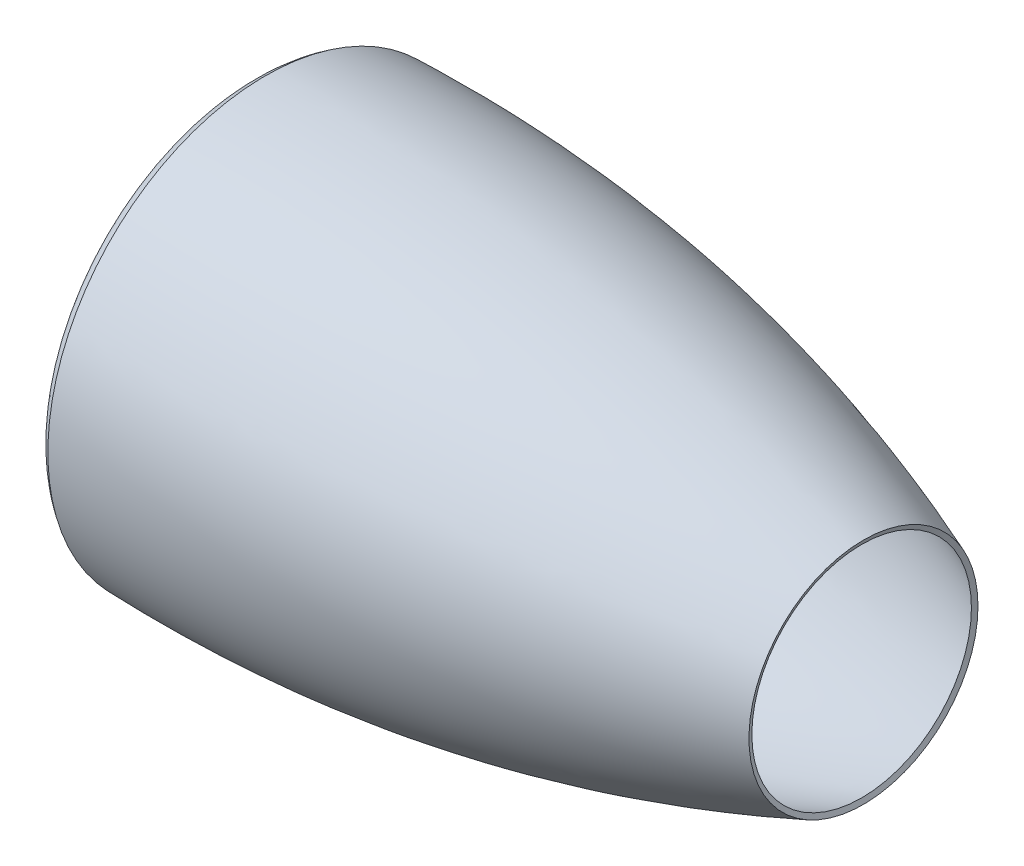
from build123d import *

# Parameters (mm, degrees)
THICKEN1_T1 = 5


with BuildPart() as body_1:
    # Surface-Revolve1: a surface, the sketch's curves turned about an axis
    with BuildLine(Plane.XY, mode=Mode.PRIVATE) as surface_revolve1_1_path:
        Line((58.164522356, 190), (33.164522356, 190))
        Line((33.164522356, 190), (25, 180))
        Line((25, 180), (0, 180))
        add(Edge.make_bspline(
            [(0, 180), (-22.199353902, 194.752810443), (0, 209.06264542)],
            knots=[0, 0, 0, 1, 1, 1], degree=2))
        add(Edge.make_bspline(
            [(0, 209.06264542), (303.114773615, 218.194510927), (585, 108)],
            knots=[0, 0, 0, 1, 1, 1], degree=2))
    surface_revolve1_1 = Shell.revolve(surface_revolve1_1_path.wire(), 360, Axis((0, 0, 0), (1, 0, 0)))
    add(Solid.thicken(surface_revolve1_1, THICKEN1_T1))


solid = body_1.part
